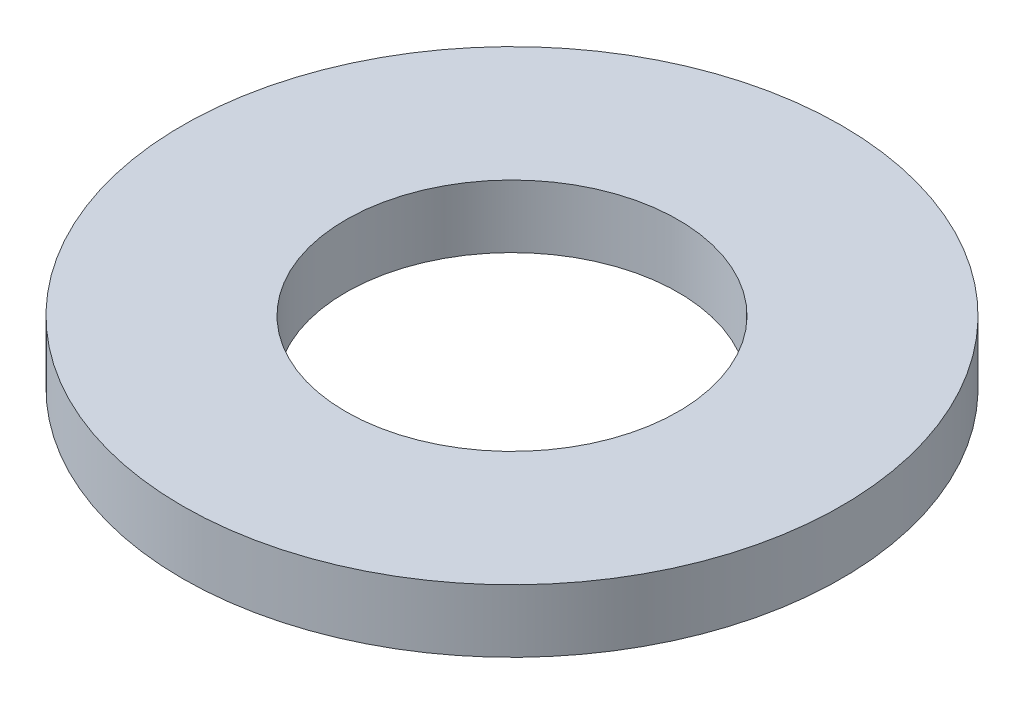
from build123d import *

# Parameters (mm, degrees)
SKETCH1_R           = 8.7884
SKETCH1_R_2         = 4.4323
BOSS_EXTRUDE1_DEPTH = 0.8382


with BuildPart() as part:
    # Sketch1 → Boss-Extrude1 (new body, symmetric)
    with BuildSketch(Plane(origin=(0, 0, 0), x_dir=(1, 0, 0), z_dir=(0, 1, 0))):
        Circle(SKETCH1_R)
        Circle(SKETCH1_R_2, mode=Mode.SUBTRACT)
    extrude(amount=BOSS_EXTRUDE1_DEPTH, both=True)


solid = part.part
